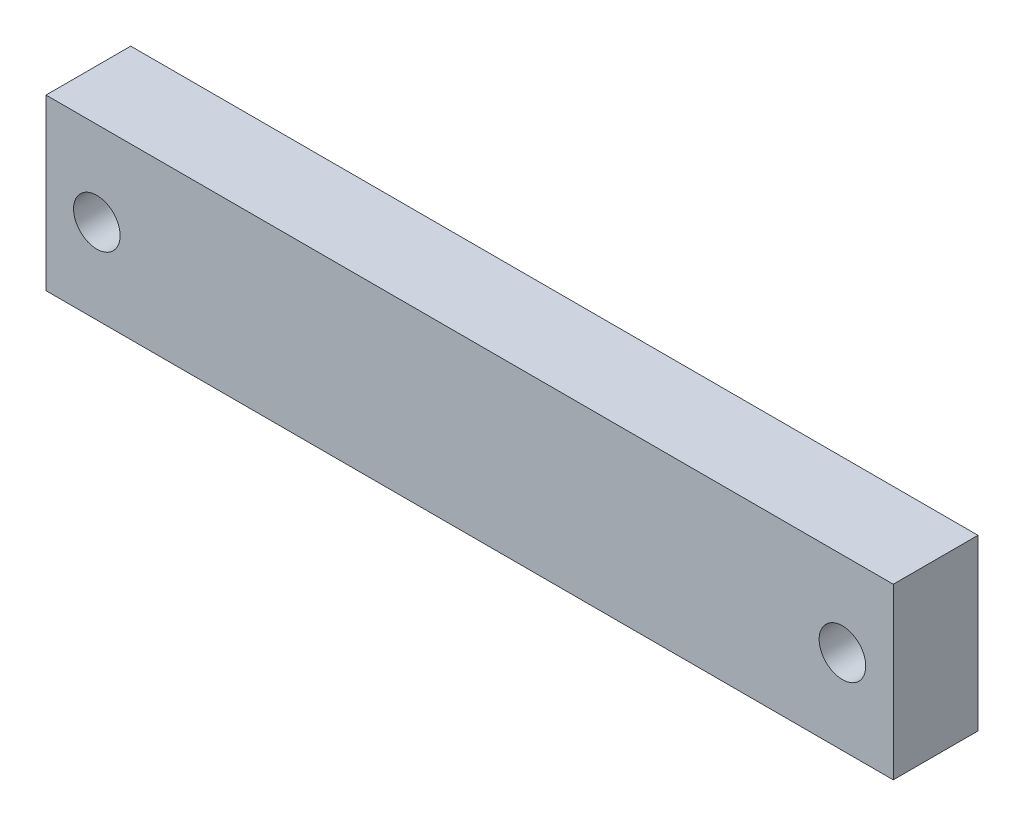
from build123d import *

# Parameters (mm, degrees)
SKETCH1_W           = 100
SKETCH1_H           = 20
BOSS_EXTRUDE1_DEPTH = 10
SKETCH2_R           = 2.75
CUT_EXTRUDE1_DEPTH  = 11


with BuildPart() as part:
    # Sketch1 → Boss-Extrude1 (new body)
    with BuildSketch(Plane.XY.offset(10)):
        with Locations((50, 10)):
            Rectangle(SKETCH1_W, SKETCH1_H)
    extrude(amount=-BOSS_EXTRUDE1_DEPTH)

    # Sketch2 → Cut-Extrude1 (cut, through all)
    with BuildSketch(Plane.XY.offset(10)):
        with Locations((94, 10)):
            Circle(SKETCH2_R)
        with Locations((6, 10)):
            Circle(SKETCH2_R)
    extrude(amount=-CUT_EXTRUDE1_DEPTH, mode=Mode.SUBTRACT)


solid = part.part
